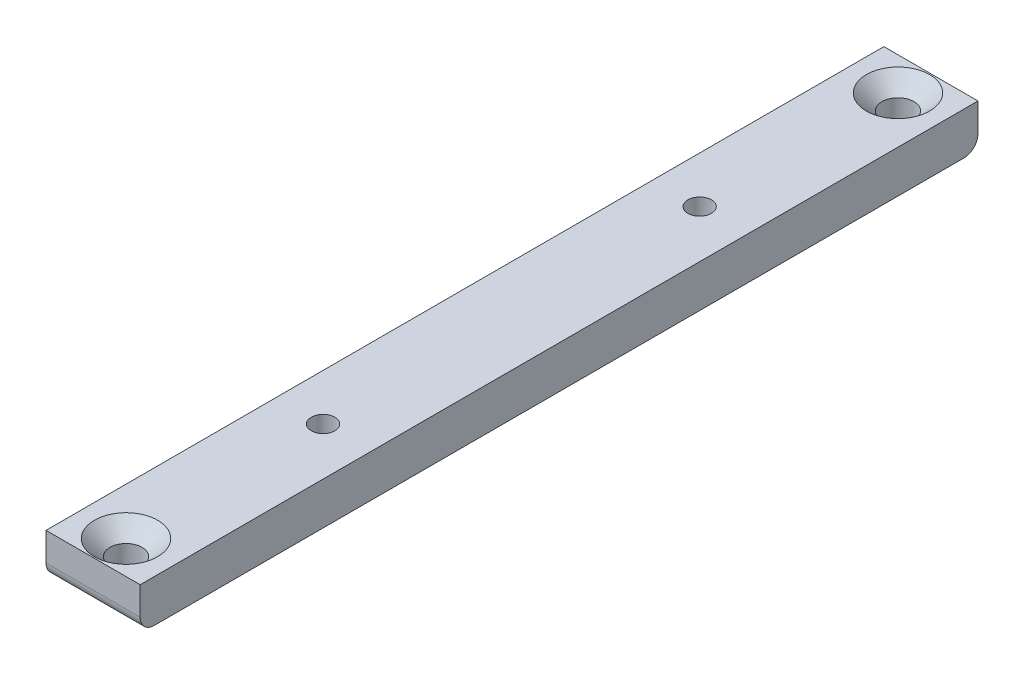
from build123d import *

# Parameters (mm, degrees)
SKETCH1_W                                            = 89
SKETCH1_H                                            = 4.5
BOSS_EXTRUDE1_DEPTH                                  = 10
FILLET1_R                                            = 1.5
CSK_FOR_M3_HEX_SOCKET_COUNTERSUNK_CAP_SC_D           = 3.4
CSK_FOR_M3_HEX_SOCKET_COUNTERSUNK_CAP_SC_CSINK_D     = 6.72
CSK_FOR_M3_HEX_SOCKET_COUNTERSUNK_CAP_SC_CSINK_ANGLE = 90
M3_TAPPED_HOLE1_D                                    = 2.5
M3_TAPPED_HOLE1_DEPTH                                = 7.5
M3_TAPPED_HOLE1_TIP                                  = 0.751075774


with BuildPart() as part:
    # Sketch1 → Boss-Extrude1 (new body)
    with BuildSketch(Plane(origin=(0, 0, 0), x_dir=(0, 0, -1), z_dir=(1, 0, 0))):
        with Locations((44.5, -2.25)):
            Rectangle(SKETCH1_W, SKETCH1_H)
    extrude(amount=BOSS_EXTRUDE1_DEPTH)

    # Fillet1
    fillet1_edges = [part.edges().sort_by_distance(p)[0] for p in [
        (5, -4.5, -89),
        (5, -4.5, 0),
    ]]
    fillet(fillet1_edges, radius=FILLET1_R)

    # CSK for M3 Hex Socket Countersunk Cap Screw1 (through all)
    with Locations(Plane(origin=(0, 0, 0), x_dir=(1, 0, 0), z_dir=(0, 1, 0))):
        with Locations((5, 3.5), (5, 85.5)):
            CounterSinkHole(CSK_FOR_M3_HEX_SOCKET_COUNTERSUNK_CAP_SC_D / 2, CSK_FOR_M3_HEX_SOCKET_COUNTERSUNK_CAP_SC_CSINK_D / 2, counter_sink_angle=CSK_FOR_M3_HEX_SOCKET_COUNTERSUNK_CAP_SC_CSINK_ANGLE)

    # M3 Tapped Hole1
    with Locations(Plane(origin=(0, 0, 0), x_dir=(1, 0, 0), z_dir=(0, 1, 0))):
        with Locations((4.933736509, 24.5), (4.933736509, 64.5)):
            Hole(M3_TAPPED_HOLE1_D / 2, depth=M3_TAPPED_HOLE1_DEPTH)
            with Locations((0, 0, -(M3_TAPPED_HOLE1_DEPTH + M3_TAPPED_HOLE1_TIP / 2))):  # 118° drill point
                Cone(0, M3_TAPPED_HOLE1_D / 2, M3_TAPPED_HOLE1_TIP, mode=Mode.SUBTRACT)


solid = part.part
